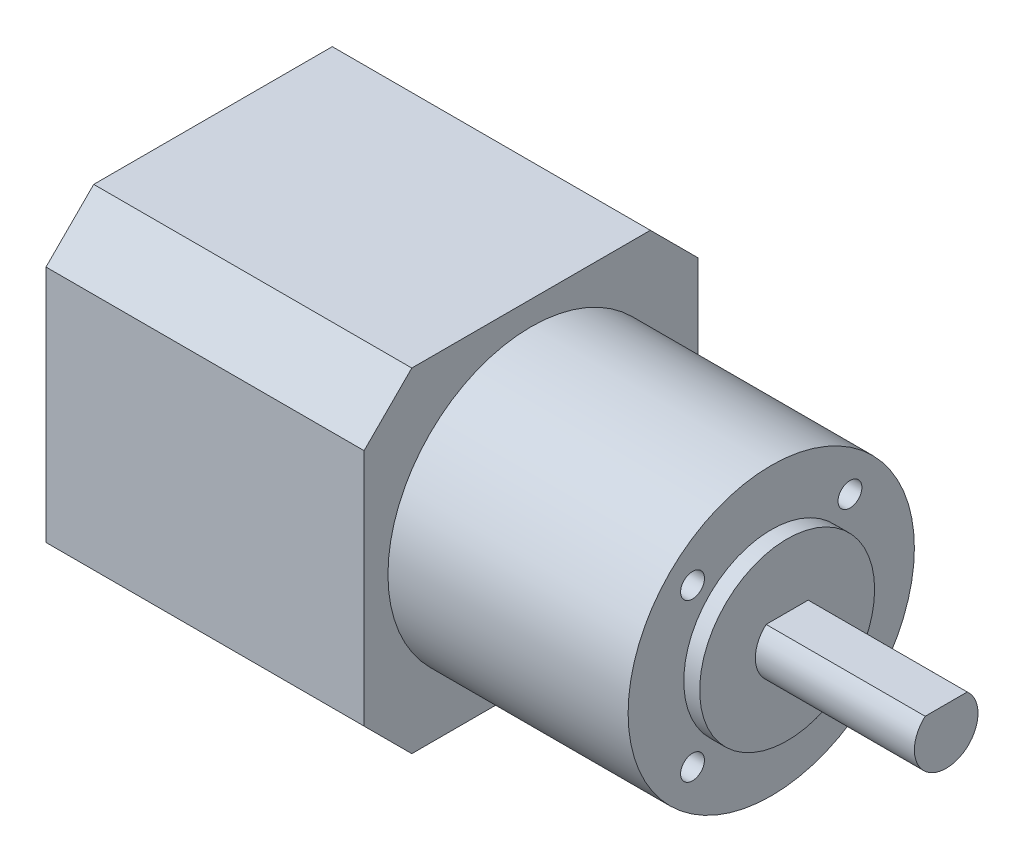
from build123d import *

# Parameters (mm, degrees)
BOSS_EXTRUDE1_DEPTH = 40
SKETCH2_R           = 18
SKETCH2_R_2         = 1.5
BOSS_EXTRUDE2_DEPTH = 30.2
SKETCH3_R           = 11
BOSS_EXTRUDE3_DEPTH = 2
BOSS_EXTRUDE4_DEPTH = 20


with BuildPart() as part:
    # Sketch1 → Boss-Extrude1 (new body)
    with BuildSketch(Plane(origin=(0, 0, 0), x_dir=(0, 0, -1), z_dir=(1, 0, 0))):
        Polygon((-21, 15), (-15, 21), (15, 21), (21, 15), (21, -15), (15, -21), (-15, -21), (-21, -15), align=None)
    extrude(amount=BOSS_EXTRUDE1_DEPTH)

    # Sketch2 → Boss-Extrude2 (add)
    with BuildSketch(Plane(origin=(40, 0, 0), x_dir=(0, 0, -1), z_dir=(1, 0, 0))):
        Circle(SKETCH2_R)
        with Locations((-9.899494937, 9.899494937)):
            Circle(SKETCH2_R_2, mode=Mode.SUBTRACT)
        with Locations((9.899494937, 9.899494937)):
            Circle(SKETCH2_R_2, mode=Mode.SUBTRACT)
        with Locations((9.899494937, -9.899494937)):
            Circle(SKETCH2_R_2, mode=Mode.SUBTRACT)
        with Locations((-9.899494937, -9.899494937)):
            Circle(SKETCH2_R_2, mode=Mode.SUBTRACT)
    extrude(amount=BOSS_EXTRUDE2_DEPTH)

    # Sketch3 → Boss-Extrude3 (add)
    with BuildSketch(Plane(origin=(70.2, 0, 0), x_dir=(0, 0, -1), z_dir=(1, 0, 0))):
        Circle(SKETCH3_R)
    extrude(amount=BOSS_EXTRUDE3_DEPTH)

    # Sketch4 → Boss-Extrude4 (add)
    with BuildSketch(Plane(origin=(72.2, 0, 0), x_dir=(0, 0, -1), z_dir=(1, 0, 0))):
        with BuildLine():
            Line((2.645751311, 3), (-2.645751311, 3))
            ThreePointArc((-2.645751311, 3), (0, -4), (2.645751311, 3))
        make_face()
    extrude(amount=BOSS_EXTRUDE4_DEPTH)


solid = part.part
